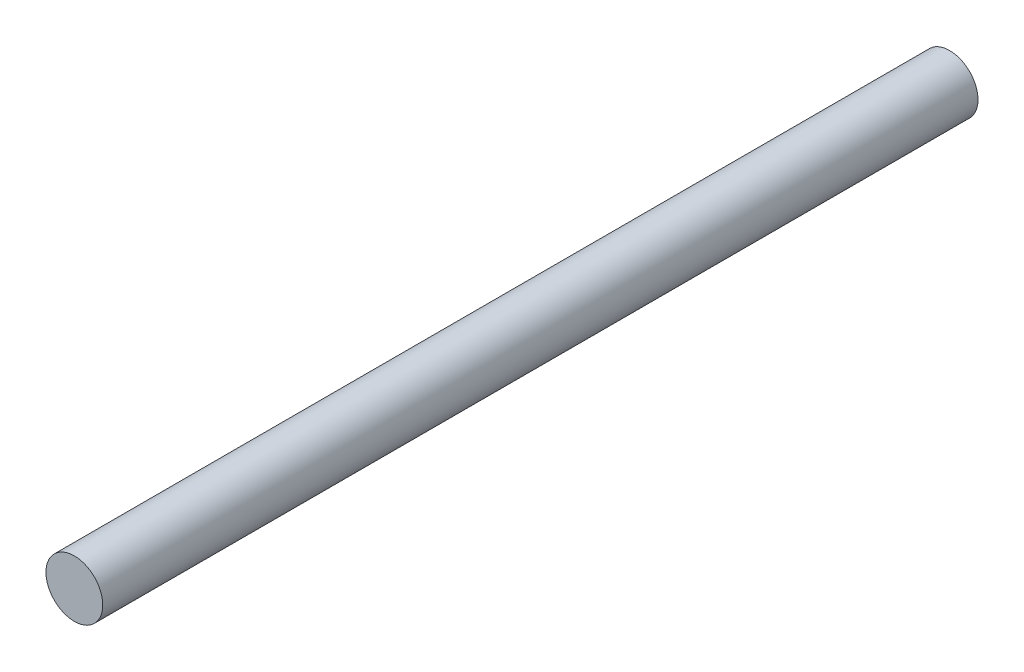
from build123d import *

# Parameters (mm, degrees)
IZIM1_R                     = 6
Y_KSEKLIK_EKSTR_ZYON1_DEPTH = 185


with BuildPart() as part:
    # Çizim1 → Yükseklik-Ekstrüzyon1 (new body)
    with BuildSketch(Plane.XY):
        Circle(IZIM1_R)
    extrude(amount=Y_KSEKLIK_EKSTR_ZYON1_DEPTH)


solid = part.part
